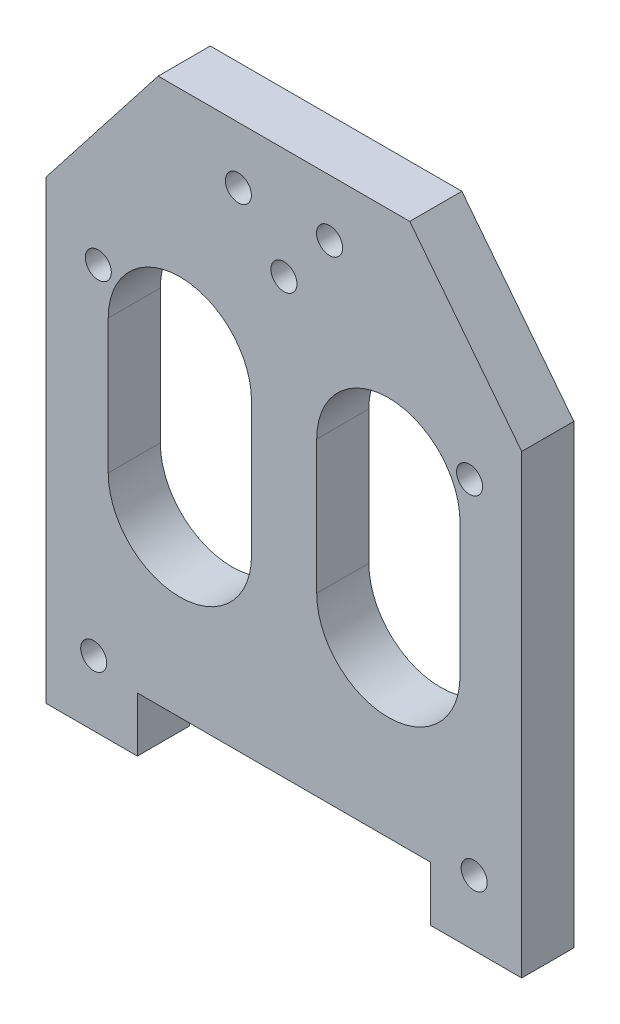
from build123d import *

# Parameters (mm, degrees)
ESBO_O2_R                = 2
RESSALTO_EXTRUS_O1_DEPTH = 8


with BuildPart() as part:
    # Esboço2 → Ressalto-extrusão1 (new body)
    with BuildSketch(Plane.XY):
        Polygon((36.5, -75), (36.5, -5), (19.311716217, 17), (-19.311716217, 17), (-36.5, -5), (-36.5, -75), (-22.499999998, -75), (-22.499999998, -66.599999996), (22.499999998, -66.599999996), (22.499999998, -75), align=None)
        with Locations((28.5, -12.7)):
            Circle(ESBO_O2_R, mode=Mode.SUBTRACT)
        with Locations((29.2, -65)):
            Circle(ESBO_O2_R, mode=Mode.SUBTRACT)
        with Locations((-29.2, -65)):
            Circle(ESBO_O2_R, mode=Mode.SUBTRACT)
        with Locations((-28.5, -12.7)):
            Circle(ESBO_O2_R, mode=Mode.SUBTRACT)
        with Locations((7, 8.3)):
            Circle(ESBO_O2_R, mode=Mode.SUBTRACT)
        with Locations((-7, 8.3)):
            Circle(ESBO_O2_R, mode=Mode.SUBTRACT)
        Circle(ESBO_O2_R, mode=Mode.SUBTRACT)
        with BuildLine():
            ThreePointArc((5.030193795, -39.591075239), (16.030188189, -50.591069634), (27.030182584, -39.591075239))
            Line((27.030182584, -39.591075239), (27.030169807, -19.087507994))
            ThreePointArc((27.030169807, -19.087507994), (16.030168558, -8.087513599), (5.030181018, -19.087507994))
            Line((5.030181018, -19.087507994), (5.030193795, -39.591075239))
        make_face(mode=Mode.SUBTRACT)
        with BuildLine():
            ThreePointArc((-26.977366802, -39.591075239), (-15.977372644, -50.591069397), (-4.977378486, -39.591075239))
            Line((-4.977378486, -39.591075239), (-4.977391172, -19.009684113))
            ThreePointArc((-4.977391172, -19.009684113), (-15.977385329, -8.009689955), (-26.977379487, -19.009684113))
            Line((-26.977379487, -19.009684113), (-26.977366802, -39.591075239))
        make_face(mode=Mode.SUBTRACT)
    extrude(amount=RESSALTO_EXTRUS_O1_DEPTH)


solid = part.part
